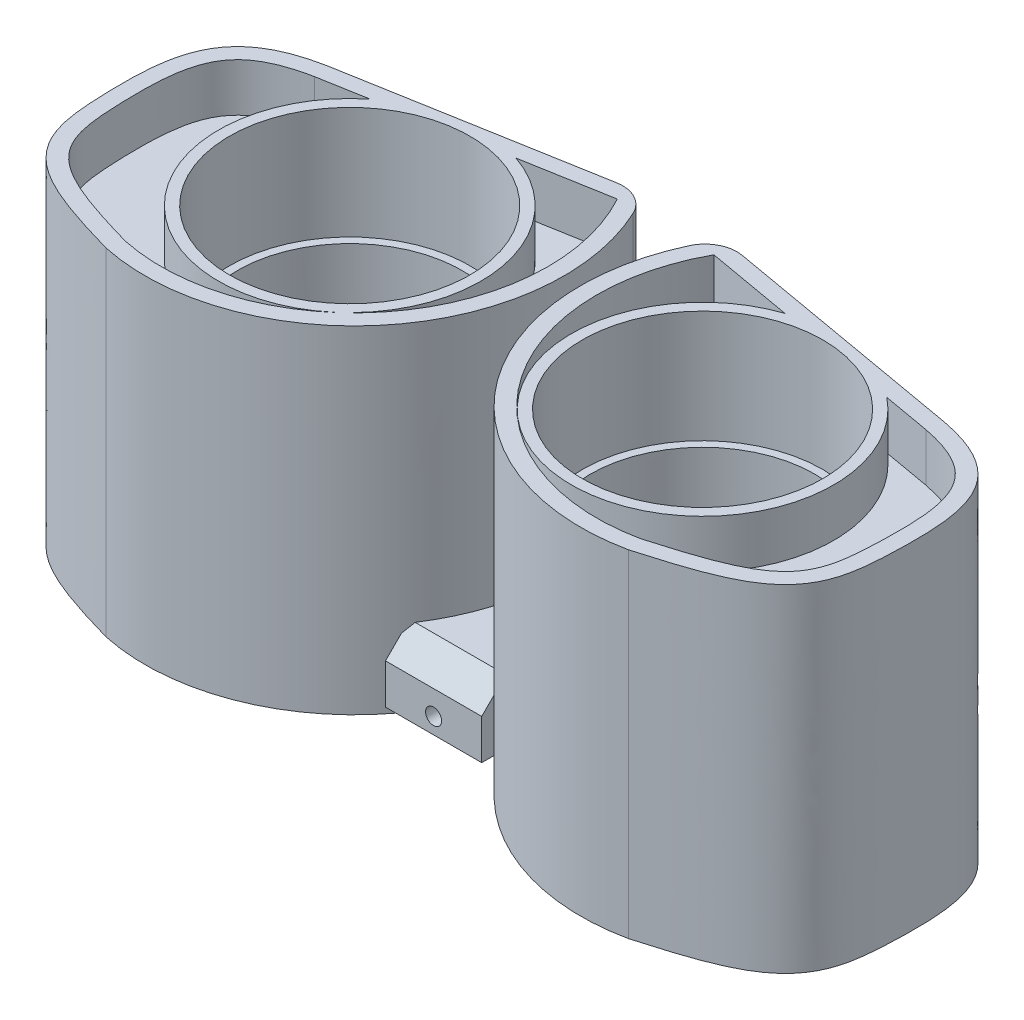
from build123d import *

# Parameters (mm, degrees)
EXTRUDE_1_DEPTH          = 21
EXTRUDE_1_2_DEPTH        = 21
CUT_EXTRUDE_5_DEPTH      = 3
CUT_EXTRUDE_6_DEPTH      = 3
SKETCH_2_R               = 7
CUT_EXTRUDE_1225_DEPTH   = 22.0000001
FILLET_1_R               = 2
FILLET_2_R               = 2
SKETCH_6_W               = 6
SKETCH_6_H               = 8
EXTRUDE_2_DEPTH          = 8
CUT_EXTRUDE_7_DEPTH      = 3.5
SKETCH_12_W              = 12
SKETCH_12_H              = 12
CUT_EXTRUDE_8_DEPTH      = 4.5000001
CUT_EXTRUDE_8_DEPTH_BACK = 3.5
SKETCH_13_R              = 0.5
CUT_EXTRUDE_9_DEPTH      = 5
SKETCH_14_R              = 8.175106469
SKETCH_14_R_2            = 7.5
EXTRUDE_3_DEPTH          = 3
SKETCH_15_R              = 7.5
CUT_EXTRUDE_10_DEPTH     = 7
EXTRUDE_5_DEPTH          = 4
SKETCH_19_R              = 0.5
CUT_EXTRUDE_11_DEPTH     = 4
CHAMFER_1_SIZE           = 1.5
CHAMFER_2_SIZE           = 1


with BuildPart() as part:
    # 草图1 → 凸台-拉伸1 (new body)
    with BuildSketch(Plane(origin=(0, 0, 0), x_dir=(1, 0, 0), z_dir=(0, 1, 0))):
        with BuildLine():
            Line((2.5, 0), (19.241731801, -2.95201902))
            add(Edge.make_bspline(
                [(16.289712781, -19.693750822), (21.129770718, -18.30937539), (24.365467079, -17.036880795), (24.930319354, -7.375094408), (24.280515787, -3.921767395), (19.241731801, -2.95201902)],
                knots=[0, 0, 0, 0, 0.38424731, 0.48424731, 1, 1, 1, 1], degree=3))
            ThreePointArc((16.289712781, -19.693750822), (2.883637018, -14.406080298), (2.5, 0))
        make_face()
    extrude(amount=EXTRUDE_1_DEPTH)

    # 草图10 → 切除-拉伸6 (cut)
    with BuildSketch(Plane(origin=(0, 21, 0), x_dir=(1, 0, 0), z_dir=(0, 1, 0))):
        with BuildLine():
            Line((19.060264326, -3.93544802), (3.010883564, -1.105509168))
            ThreePointArc((3.010883564, -1.105509168), (3.887898278, -14.089614485), (16.049007816, -18.722492691))
            add(Edge.make_bspline(
                [(16.049007816, -18.722492691), (16.920025913, -18.473121161), (17.78914031, -18.217662956), (19.075850198, -17.780244196), (19.502068288, -17.6249077), (20.33615497, -17.280474648), (20.744836841, -17.091657417), (21.333105452, -16.759285049), (21.524991654, -16.640149037), (21.896670299, -16.377866287), (22.077277299, -16.233576984), (22.408411373, -15.923221016), (22.560329563, -15.756228886), (22.832571371, -15.394897048), (22.953902056, -15.198182278), (23.260109597, -14.583370873), (23.38720842, -14.147493785), (23.553865264, -13.246192341), (23.596863689, -12.79302286), (23.656166309, -11.887178772), (23.671885397, -11.433841556), (23.692971487, -10.526858637), (23.695815534, -10.073137752), (23.669767406, -9.164750262), (23.641021094, -8.707938015), (23.522406096, -7.804279886), (23.433534417, -7.357660735), (23.212324366, -6.706527424), (23.124774871, -6.496572645), (22.914786728, -6.094570534), (22.791278459, -5.901338245), (22.506656738, -5.541845028), (22.348740386, -5.37915459), (22.00509679, -5.084169897), (21.818073391, -4.951017446), (21.231651438, -4.595604637), (20.815073756, -4.418550251), (19.95339814, -4.131083131), (19.508411447, -4.021962474), (19.060264326, -3.93544802)],
                knots=[0, 0, 0, 0, 0.125, 0.125, 0.1875, 0.1875, 0.25, 0.25, 0.28125, 0.28125, 0.3125, 0.3125, 0.34375, 0.34375, 0.375, 0.375, 0.4375, 0.4375, 0.5, 0.5, 0.5625, 0.5625, 0.625, 0.625, 0.6875, 0.6875, 0.75, 0.75, 0.78125, 0.78125, 0.8125, 0.8125, 0.84375, 0.84375, 0.875, 0.875, 0.9375, 0.9375, 1, 1, 1, 1], degree=3))
        make_face()
    extrude(amount=-CUT_EXTRUDE_6_DEPTH, mode=Mode.SUBTRACT)


with BuildPart() as body_2:
    # 草图1 → Extrude 1 2 (new body)
    with BuildSketch(Plane(origin=(0, 0, 0), x_dir=(1, 0, 0), z_dir=(0, 1, 0))):
        with BuildLine():
            Line((-2.5, 0), (-19.241731801, -2.95201902))
            add(Edge.make_bspline(
                [(-16.289712781, -19.693750822), (-21.129770718, -18.30937539), (-24.365467079, -17.036880795), (-24.930319354, -7.375094408), (-24.280515787, -3.921767395), (-19.241731801, -2.95201902)],
                knots=[0, 0, 0, 0, 0.38424731, 0.48424731, 1, 1, 1, 1], degree=3))
            ThreePointArc((-16.289712781, -19.693750822), (-2.883637018, -14.406080298), (-2.5, 0))
        make_face()
    extrude(amount=EXTRUDE_1_2_DEPTH)

    # 草图9 → 切除-拉伸5 (cut)
    with BuildSketch(Plane(origin=(0, 21, 0), x_dir=(1, 0, 0), z_dir=(0, 1, 0))):
        with BuildLine():
            Line((-3.010883564, -1.105509168), (-19.060264326, -3.93544802))
            add(Edge.make_bspline(
                [(-19.060264326, -3.93544802), (-19.508216734, -4.021924885), (-19.949209876, -4.130013985), (-20.593817654, -4.344575051), (-20.80583512, -4.424951748), (-21.222214191, -4.609480673), (-21.427618699, -4.714387114), (-21.81720082, -4.950476039), (-22.002367105, -5.081982754), (-22.348522561, -5.378812904), (-22.509862914, -5.545621897), (-22.791306906, -5.901650038), (-22.913464376, -6.092247394), (-23.124561611, -6.495957516), (-23.213330058, -6.709349312), (-23.432492832, -7.354872491), (-23.521649384, -7.799848963), (-23.640808498, -8.704995167), (-23.669482184, -9.159390938), (-23.695785918, -10.06757243), (-23.693039263, -10.521963617), (-23.671996172, -11.431039842), (-23.656215156, -11.886330136), (-23.596853082, -12.793287312), (-23.553751506, -13.245080327), (-23.430284393, -13.915382929), (-23.377766963, -14.138829281), (-23.241740603, -14.574596484), (-23.158986036, -14.785731565), (-22.95753614, -15.191548255), (-22.837395421, -15.387866535), (-22.562766455, -15.753605979), (-22.410204286, -15.921333626), (-22.079661624, -16.231546653), (-21.900758382, -16.374775838), (-21.527768136, -16.638391617), (-21.335353924, -16.757946235), (-20.745847427, -17.09122233), (-20.336797544, -17.28019005), (-19.502562274, -17.624722934), (-19.076673871, -17.77995258), (-17.789552289, -18.21754609), (-16.92022558, -18.473063997), (-16.049007816, -18.722492691)],
                knots=[0, 0, 0, 0, 0.0625, 0.0625, 0.09375, 0.09375, 0.125, 0.125, 0.15625, 0.15625, 0.1875, 0.1875, 0.21875, 0.21875, 0.25, 0.25, 0.3125, 0.3125, 0.375, 0.375, 0.4375, 0.4375, 0.5, 0.5, 0.5625, 0.5625, 0.59375, 0.59375, 0.625, 0.625, 0.65625, 0.65625, 0.6875, 0.6875, 0.71875, 0.71875, 0.75, 0.75, 0.8125, 0.8125, 0.875, 0.875, 1, 1, 1, 1], degree=3))
            ThreePointArc((-16.049007816, -18.722492691), (-3.887898278, -14.089614485), (-3.010883564, -1.105509168))
        make_face()
    extrude(amount=-CUT_EXTRUDE_5_DEPTH, mode=Mode.SUBTRACT)


with BuildPart() as cut_extrude_1225_tool:
    # 草图2 → Cut-Extrude 1225 (new body, through all)
    with BuildSketch(Plane(origin=(0, 21, 0), x_dir=(1, 0, 0), z_dir=(0, 1, 0))):
        with Locations((11, -9.8)):
            Circle(SKETCH_2_R)
        with Locations((-11, -9.8)):
            Circle(SKETCH_2_R)
    extrude(amount=-CUT_EXTRUDE_1225_DEPTH)


with BuildPart() as part_1:
    add(part.part)

    # Cut-Extrude 1225: cut by cut_extrude_1225_tool
    add(cut_extrude_1225_tool.part, mode=Mode.SUBTRACT)

    # 圆角2
    fillet_2_edges = [part_1.edges().sort_by_distance(p)[0] for p in [
        (2.5, 10.5, 0),
    ]]
    fillet(fillet_2_edges, radius=FILLET_2_R)



with BuildPart() as body_2_1:
    add(body_2.part)

    # Cut-Extrude 1225: cut by cut_extrude_1225_tool
    add(cut_extrude_1225_tool.part, mode=Mode.SUBTRACT)

    # 圆角1
    fillet_1_edges = [body_2_1.edges().sort_by_distance(p)[0] for p in [
        (-2.5, 10.5, 0),
    ]]
    fillet(fillet_1_edges, radius=FILLET_1_R)


with BuildPart() as part_2:
    add(part_1.part)

    add(body_2_1.part)  # 凸台-拉伸2 merges body 2
    # 草图6 → 凸台-拉伸2 (add)
    with BuildSketch(Plane(origin=(0, 0, 0), x_dir=(1, 0, 0), z_dir=(0, 1, 0))):
        with Locations((0, -6)):
            Rectangle(SKETCH_6_W, SKETCH_6_H)
    extrude(amount=EXTRUDE_2_DEPTH)

    # 草图11 → 切除-拉伸7 (cut)
    with BuildSketch(Plane.XZ):
        with BuildLine():
            Line((-19.096580565, 3.738766231), (-3.77459596, 1.037086947))
            ThreePointArc((-3.77459596, 1.037086947), (-3.01309206, 1.153937694), (-2.479576856, 1.709728855))
            ThreePointArc((-2.479576856, 1.709728855), (-2.24233826, 2.249475337), (-2.031314538, 2.8))
            Line((-2.031314538, 2.8), (2.031314538, 2.8))
            ThreePointArc((2.031314538, 2.8), (2.24233826, 2.249475337), (2.479576856, 1.709728855))
            ThreePointArc((2.479576856, 1.709728855), (3.01309206, 1.153937694), (3.77459596, 1.037086947))
            Line((3.77459596, 1.037086947), (19.096580565, 3.738766231))
            add(Edge.make_bspline(
                [(19.096580565, 3.738766231), (19.555621979, 3.827326982), (20.007379405, 3.938260311), (20.667494069, 4.158477044), (20.884573407, 4.240970753), (21.310864134, 4.430124365), (21.521373257, 4.537659228), (21.921205492, 4.779337926), (22.111278601, 4.913660292), (22.467184391, 5.215509722), (22.634116108, 5.385076381), (22.927408175, 5.747338347), (23.055393925, 5.94087753), (23.277643736, 6.350379213), (23.372264355, 6.567771824), (23.606994699, 7.227180522), (23.703505432, 7.68176447), (23.833223359, 8.606741477), (23.86527304, 9.073788488), (23.895620095, 10.004854163), (23.89370614, 10.470645668), (23.873233173, 11.402480647), (23.857325536, 11.869169508), (23.797314112, 12.799250202), (23.75341081, 13.262462928), (23.585700724, 14.178380564), (23.453829662, 14.633865576), (23.148701106, 15.259757209), (23.028247824, 15.461257619), (22.750997882, 15.840472942), (22.597052106, 16.014833269), (22.096219053, 16.499105522), (21.707716486, 16.771433545), (20.906221847, 17.235140144), (20.488347929, 17.431516584), (19.635289147, 17.788410739), (19.199454228, 17.948571897), (17.880961765, 18.399336423), (16.989974153, 18.66118069), (16.097047721, 18.916774011)],
                knots=[0, 0, 0, 0, 0.0625, 0.0625, 0.09375, 0.09375, 0.125, 0.125, 0.15625, 0.15625, 0.1875, 0.1875, 0.21875, 0.21875, 0.25, 0.25, 0.3125, 0.3125, 0.375, 0.375, 0.4375, 0.4375, 0.5, 0.5, 0.5625, 0.5625, 0.625, 0.625, 0.65625, 0.65625, 0.6875, 0.6875, 0.75, 0.75, 0.8125, 0.8125, 0.875, 0.875, 1, 1, 1, 1], degree=3))
            ThreePointArc((16.097047721, 18.916774011), (6.77753273, 17.11402114), (1.536202079, 9.2))
            Line((1.536202079, 9.2), (-1.536202079, 9.2))
            ThreePointArc((-1.536202079, 9.2), (-6.77753273, 17.11402114), (-16.097047721, 18.916774011))
            add(Edge.make_bspline(
                [(-16.097047721, 18.916774011), (-16.988723772, 18.661538602), (-17.878439422, 18.40006208), (-19.194903838, 17.950195465), (-19.630991369, 17.790036508), (-20.482981619, 17.433932034), (-20.899772042, 17.238219407), (-21.49806118, 16.893046125), (-21.692925959, 16.769229959), (-22.069719352, 16.496777951), (-22.253176144, 16.346420337), (-22.58941986, 16.02308429), (-22.743129518, 15.849659838), (-23.01822447, 15.476443061), (-23.140361224, 15.274964284), (-23.451832929, 14.641594982), (-23.581977137, 14.194332647), (-23.752650889, 13.270882708), (-23.796798777, 12.805112521), (-23.857076214, 11.875131325), (-23.872982624, 11.409653668), (-23.893629096, 10.478316217), (-23.895700141, 10.012365084), (-23.865614885, 9.079291487), (-23.833566922, 8.610613256), (-23.736607581, 7.917103565), (-23.69602447, 7.687299073), (-23.591869816, 7.23148862), (-23.52785343, 7.0044583), (-23.371173707, 6.565110178), (-23.278417813, 6.352036561), (-23.056444217, 5.942583526), (-22.925249527, 5.744302651), (-22.631626942, 5.382377191), (-22.469146973, 5.217493958), (-22.11562817, 4.917035148), (-21.922825107, 4.780417401), (-21.322833655, 4.417452073), (-20.896141589, 4.235168433), (-20.011991142, 3.939391224), (-19.556039383, 3.82740751), (-19.096580565, 3.738766231)],
                knots=[0, 0, 0, 0, 0.125, 0.125, 0.1875, 0.1875, 0.25, 0.25, 0.28125, 0.28125, 0.3125, 0.3125, 0.34375, 0.34375, 0.375, 0.375, 0.4375, 0.4375, 0.5, 0.5, 0.5625, 0.5625, 0.625, 0.625, 0.6875, 0.6875, 0.71875, 0.71875, 0.75, 0.75, 0.78125, 0.78125, 0.8125, 0.8125, 0.84375, 0.84375, 0.875, 0.875, 0.9375, 0.9375, 1, 1, 1, 1], degree=3))
        make_face()
    extrude(amount=-CUT_EXTRUDE_7_DEPTH, mode=Mode.SUBTRACT)

    # 草图12 → 切除-拉伸8 (cut, two sides)
    with BuildSketch(Plane.XZ.offset(-3.5)) as cut_extrude_8_sk:
        with Locations((-11, 9.8)):
            Rectangle(SKETCH_12_W, SKETCH_12_H)
        with Locations((11, 9.8)):
            Rectangle(SKETCH_12_W, SKETCH_12_H)
    extrude(amount=CUT_EXTRUDE_8_DEPTH, mode=Mode.SUBTRACT)
    extrude(cut_extrude_8_sk.sketch, amount=-CUT_EXTRUDE_8_DEPTH_BACK, mode=Mode.SUBTRACT)

    # 草图13 → 切除-拉伸9 (cut)
    with BuildSketch(Plane.XZ.offset(-3.5)):
        with Locations((22.5, 10)):
            Circle(SKETCH_13_R)
        with Locations((-22.5, 10)):
            Circle(SKETCH_13_R)
    extrude(amount=-CUT_EXTRUDE_9_DEPTH, mode=Mode.SUBTRACT)

    # 草图14 → 凸台-拉伸3 (add)
    with BuildSketch(Plane(origin=(0, 18, 0), x_dir=(1, 0, 0), z_dir=(0, 1, 0))):
        with Locations((-11, -9.8)):
            Circle(SKETCH_14_R)
        with Locations((-11, -9.8)):
            Circle(SKETCH_14_R_2, mode=Mode.SUBTRACT)
        with Locations((11, -9.8)):
            Circle(SKETCH_14_R)
        with Locations((11, -9.8)):
            Circle(SKETCH_14_R_2, mode=Mode.SUBTRACT)
    extrude(amount=EXTRUDE_3_DEPTH)

    # 草图15 → 切除-拉伸10 (cut)
    with BuildSketch(Plane(origin=(0, 21, 0), x_dir=(1, 0, 0), z_dir=(0, 1, 0))):
        with Locations((-11, -9.8)):
            Circle(SKETCH_15_R)
        with Locations((11, -9.8)):
            Circle(SKETCH_15_R)
    extrude(amount=-CUT_EXTRUDE_10_DEPTH, mode=Mode.SUBTRACT)

    # 草图18 → 凸台-拉伸5 (add)
    with BuildSketch(Plane.XZ.offset(-0.8)):
        Polygon((-0.891043368, 10), (-3, 14.569576636), (-3, 15.569576636), (3, 15.569576636), (3, 14.569576636), (0.891043368, 10), align=None)
    extrude(amount=-EXTRUDE_5_DEPTH)

    # 草图19 → 切除-拉伸11 (cut)
    with BuildSketch(Plane.XY.offset(15.569576636)):
        with Locations((0, 1.8)):
            Circle(SKETCH_19_R)
    extrude(amount=-CUT_EXTRUDE_11_DEPTH, mode=Mode.SUBTRACT)

    # 倒角1
    chamfer_1_edges = [part_2.edges().sort_by_distance(p)[0] for p in [
        (0, 4.8, 15.569576636),
    ]]
    chamfer(chamfer_1_edges, length=CHAMFER_1_SIZE)

    # 倒角2
    chamfer_2_edges = [part_2.edges().sort_by_distance(p)[0] for p in [
        (0, 8, 10),
    ]]
    chamfer(chamfer_2_edges, length=CHAMFER_2_SIZE)


solid = part_2.part
